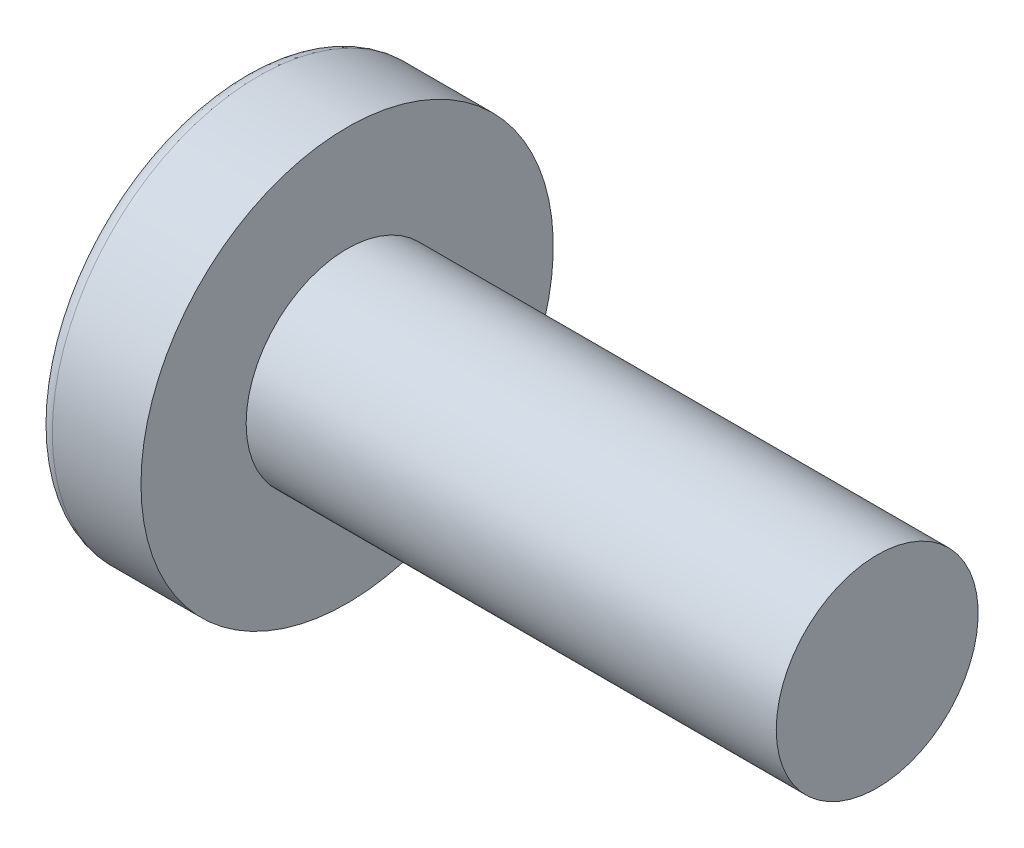
from build123d import *

# Parameters (mm, degrees)
SKETCH3_W = 0.74
SKETCH3_H = 2.9
SKETCH4_W = 0.37
SKETCH4_H = 0.37


with BuildPart() as part:
    # BodySke → Base-Revolve (revolve)
    with BuildSketch(Plane.XY):
        with BuildLine():
            Line((3, 2.4), (3, 4.9))
            Line((3, 4.9), (0.891938874, 4.9))
            ThreePointArc((0.891938874, 4.9), (0.668733198, 4.822452166), (0.541689281, 4.623217923))
            ThreePointArc((0.541689281, 4.623217923), (0.135883931, 2.327421923), (0, 0))
            Line((0, 0), (15.6, 0))
            Line((15.6, 0), (15.6, 2.4))
            Line((15.6, 2.4), (3, 2.4))
        make_face()
    revolve(axis=Axis((-25.4, 0, 0), (1, 0, 0)))

    # Sketch3 → Cut-Loft1 section 0
    with BuildSketch(Plane(origin=(0, 0, 0), x_dir=(0, 0, -1), z_dir=(1, 0, 0))):
        Rectangle(SKETCH3_W, SKETCH3_H)
    # Sketch4 → Cut-Loft1 section 1
    with BuildSketch(Plane(origin=(1.76, 0, 0), x_dir=(0, 0, -1), z_dir=(1, 0, 0))):
        Rectangle(SKETCH4_W, SKETCH4_H)
    loft(mode=Mode.SUBTRACT)


solid = part.part
